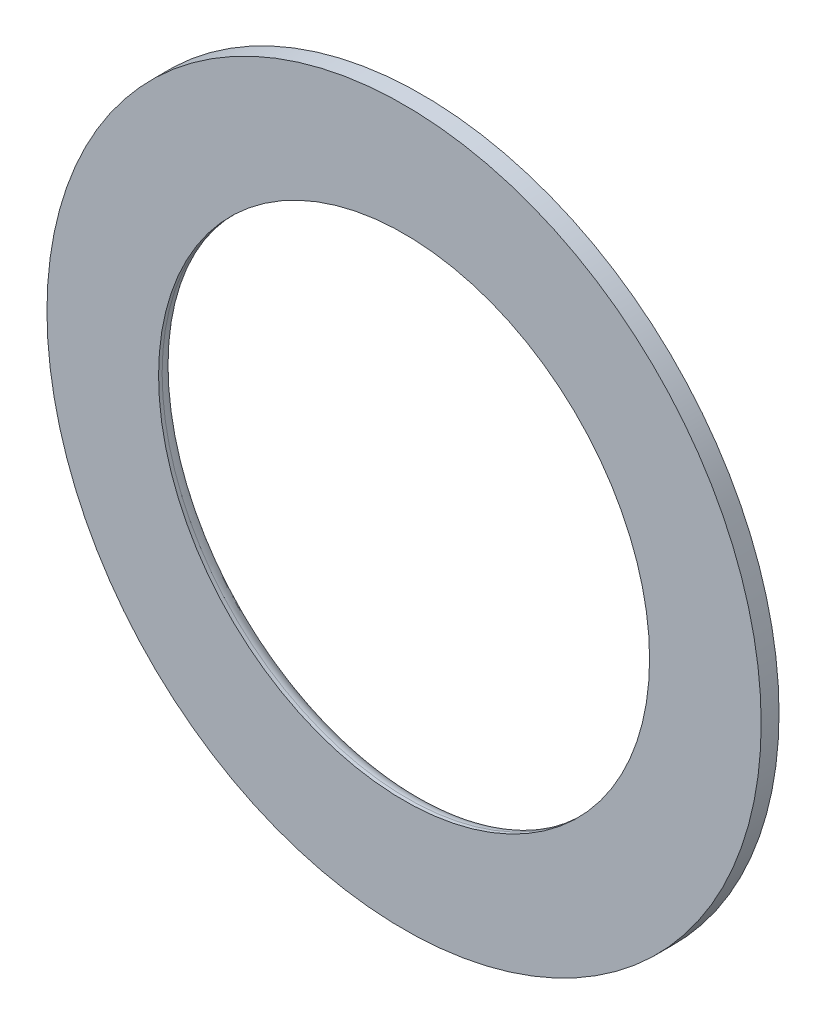
from build123d import *

# Parameters (mm, degrees)
SKETCH1_R           = 40
SKETCH1_R_2         = 27.5
BOSS_EXTRUDE1_DEPTH = 2
FILLET1_R           = 1.6


with BuildPart() as part:
    # Sketch1 → Boss-Extrude1 (new body)
    with BuildSketch(Plane.XY):
        Circle(SKETCH1_R)
        Circle(SKETCH1_R_2, mode=Mode.SUBTRACT)
    extrude(amount=BOSS_EXTRUDE1_DEPTH)

    # Fillet1
    fillet1_edges = [part.edges().sort_by_distance(p)[0] for p in [
        (-27.5, 0, 0),
    ]]
    fillet(fillet1_edges, radius=FILLET1_R)


solid = part.part
